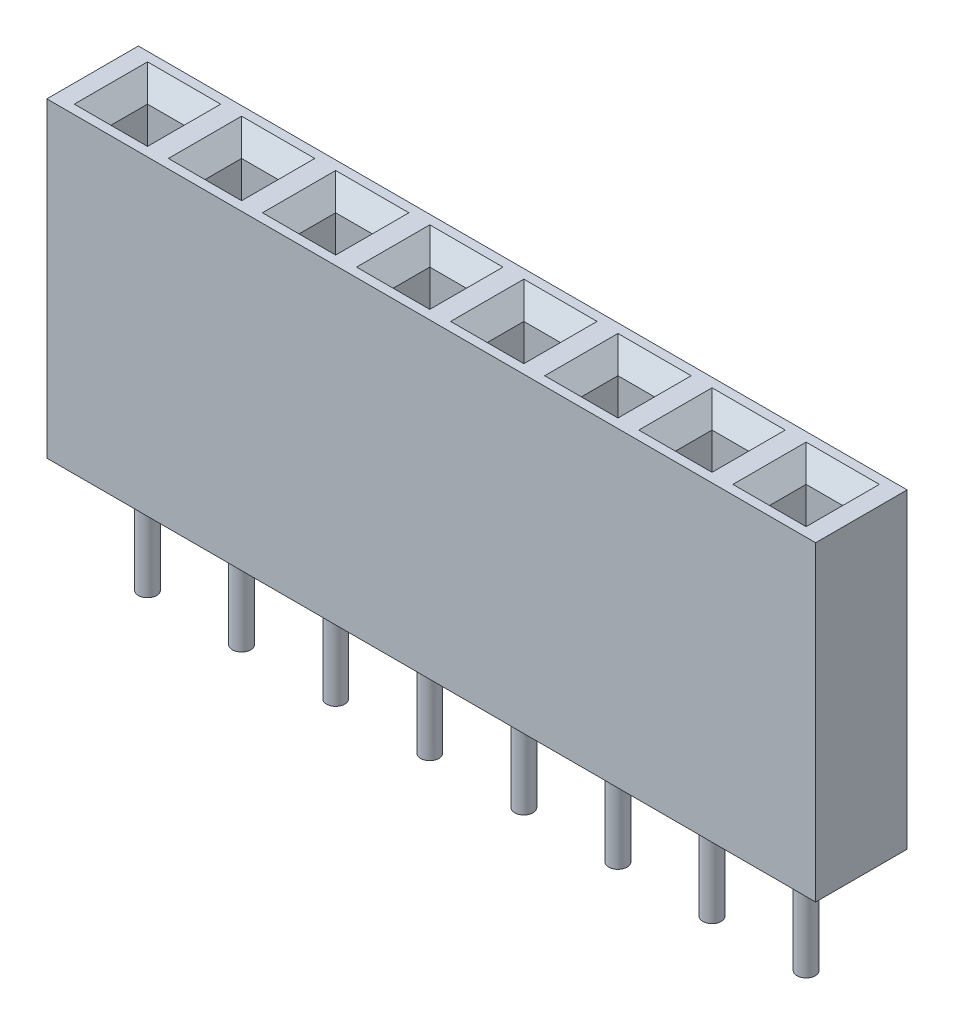
from build123d import *

# Parameters (mm, degrees)
SKETCH1_W           = 21
SKETCH1_H           = 2.5
BOSS_EXTRUDE1_DEPTH = 8.5
SKETCH2_W           = 1
SKETCH2_H           = 1
CUT_EXTRUDE1_DEPTH  = 5
CHAMFER1_SIZE       = 0.5
SKETCH4_R           = 0.25
BOSS_EXTRUDE2_DEPTH = 6.5


with BuildPart() as part:
    # Sketch1 → Boss-Extrude1 (new body)
    with BuildSketch(Plane(origin=(0, 0, 0), x_dir=(1, 0, 0), z_dir=(0, 1, 0))):
        with Locations((10.5, 1.25)):
            Rectangle(SKETCH1_W, SKETCH1_H)
    extrude(amount=BOSS_EXTRUDE1_DEPTH)

    # Sketch2 → Cut-Extrude1 (cut)
    with BuildSketch(Plane(origin=(0, 8.5, 0), x_dir=(1, 0, 0), z_dir=(0, 1, 0))):
        with Locations((1.5, 1.25)):
            Rectangle(SKETCH2_W, SKETCH2_H)
        with Locations((4.07, 1.25)):
            Rectangle(SKETCH2_W, SKETCH2_H)
        with Locations((6.64, 1.25)):
            Rectangle(SKETCH2_W, SKETCH2_H)
        with Locations((9.21, 1.25)):
            Rectangle(SKETCH2_W, SKETCH2_H)
        with Locations((11.78, 1.25)):
            Rectangle(SKETCH2_W, SKETCH2_H)
        with Locations((14.35, 1.25)):
            Rectangle(SKETCH2_W, SKETCH2_H)
        with Locations((16.92, 1.25)):
            Rectangle(SKETCH2_W, SKETCH2_H)
        with Locations((19.49, 1.25)):
            Rectangle(SKETCH2_W, SKETCH2_H)
    extrude(amount=-CUT_EXTRUDE1_DEPTH, mode=Mode.SUBTRACT)

    # Chamfer1
    chamfer1_edges = [part.edges().sort_by_distance(p)[0] for p in [
        (1, 8.5, -1.25),
        (1.5, 8.5, -0.75),
        (2, 8.5, -1.25),
        (1.5, 8.5, -1.75),
        (3.57, 8.5, -1.25),
        (4.07, 8.5, -0.75),
        (4.57, 8.5, -1.25),
        (4.07, 8.5, -1.75),
        (6.14, 8.5, -1.25),
        (6.64, 8.5, -0.75),
        (7.14, 8.5, -1.25),
        (6.64, 8.5, -1.75),
        (8.71, 8.5, -1.25),
        (9.21, 8.5, -0.75),
        (9.71, 8.5, -1.25),
        (9.21, 8.5, -1.75),
        (11.28, 8.5, -1.25),
        (11.78, 8.5, -0.75),
        (12.28, 8.5, -1.25),
        (11.78, 8.5, -1.75),
        (13.85, 8.5, -1.25),
        (14.35, 8.5, -0.75),
        (14.85, 8.5, -1.25),
        (14.35, 8.5, -1.75),
        (16.42, 8.5, -1.25),
        (16.92, 8.5, -0.75),
        (17.42, 8.5, -1.25),
        (16.92, 8.5, -1.75),
        (18.99, 8.5, -1.25),
        (19.49, 8.5, -0.75),
        (19.99, 8.5, -1.25),
        (19.49, 8.5, -1.75),
    ]]
    chamfer(chamfer1_edges, length=CHAMFER1_SIZE)

    # Sketch4 → Boss-Extrude2 (add)
    with BuildSketch(Plane(origin=(0, 3.5, 0), x_dir=(1, 0, 0), z_dir=(0, 1, 0))):
        with Locations((1.5, 1.25)):
            Circle(SKETCH4_R)
        with Locations((4.07, 1.25)):
            Circle(SKETCH4_R)
        with Locations((6.64, 1.25)):
            Circle(SKETCH4_R)
        with Locations((9.21, 1.25)):
            Circle(SKETCH4_R)
        with Locations((11.78, 1.25)):
            Circle(SKETCH4_R)
        with Locations((14.35, 1.25)):
            Circle(SKETCH4_R)
        with Locations((16.92, 1.25)):
            Circle(SKETCH4_R)
        with Locations((19.49, 1.25)):
            Circle(SKETCH4_R)
    extrude(amount=-BOSS_EXTRUDE2_DEPTH)


solid = part.part
